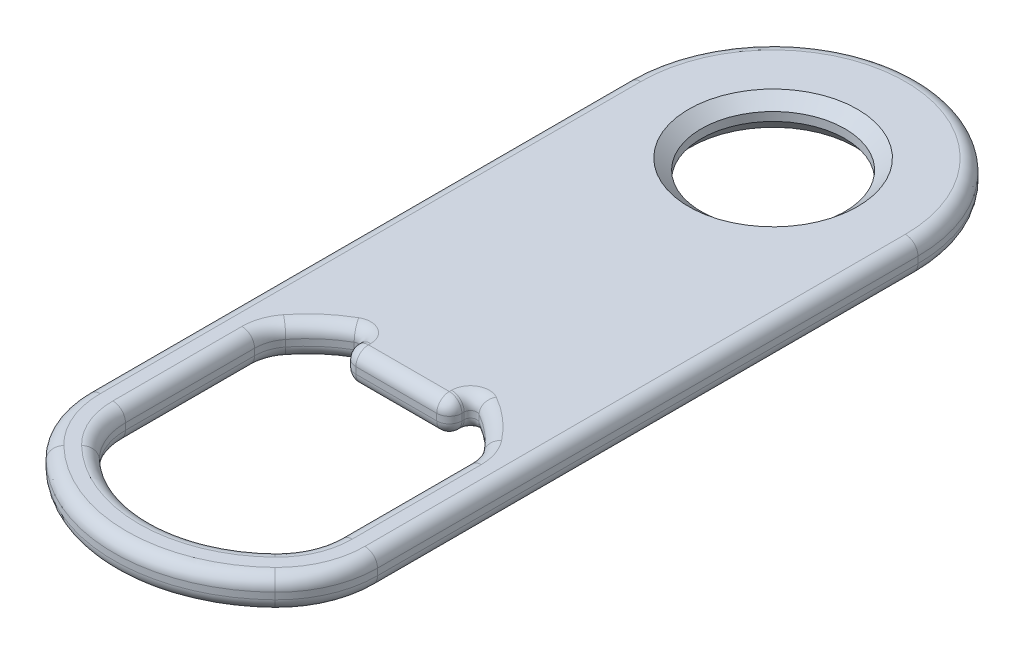
from build123d import *

# Parameters (mm, degrees)
BOSS_EXTRUDE1_DEPTH   = 2.52
CUT_EXTRUDE1_DEPTH    = 10
FILLET1_R             = 1
FILLET2_R             = 8
FILLET3_R             = 5
FILLET4_R             = 3
FILLET5_R             = 0.5
FILLET6_R             = 1
FILLET7_R             = 1
CHAMFER1_SIZE         = 1
CHAMFER1_SIZE2        = 0.839099631
CHAMFER1_PART_2_SIZE  = 1
CHAMFER1_PART_2_SIZE2 = 0.839099631


with BuildPart() as part:
    # Sketch3 → Boss-Extrude1 (new body)
    with BuildSketch(Plane(origin=(0, 11.24, 0), x_dir=(0, 0, 1), z_dir=(0, -1, 0))):
        with BuildLine():
            Line((-5.7, 0), (-12.000001825, 0))
            Line((-12.000001825, 0), (-12.000001825, 11.5))
            Line((-12.000001825, 11.5), (45.406310527, 11.5))
            ThreePointArc((45.406310527, 11.5), (50.46030749, 6.709778353), (52.322559669, 0))
            Line((52.322559669, 0), (49.322559669, 0))
            ThreePointArc((49.322559669, 0), (48.068036881, 4.857481326), (44.618252316, 8.499999508))
            Line((44.618252316, 8.499999508), (31.732809444, 8.499999508))
            ThreePointArc((31.732809444, 8.499999508), (29.503647996, 6.63570395), (27.906627074, 4.207889529))
            Line((27.906627074, 4.207889529), (29.906623676, 4.207889529))
            Line((29.906623676, 4.207889529), (29.906623676, 0))
            Line((29.906623676, 0), (5.7, 0))
            ThreePointArc((5.7, 0), (0, 5.7), (-5.7, 0))
        make_face()
    extrude(amount=-BOSS_EXTRUDE1_DEPTH)

    # Sketch5 → Cut-Extrude1 (cut)
    with BuildSketch(Plane(origin=(0, 11.24, 0), x_dir=(0, 0, 1), z_dir=(0, -1, 0))):
        with BuildLine():
            Line((0, 11.5), (0, 20.081542109))
            Line((0, 20.081542109), (-17.206571574, 20.081542109))
            Line((-17.206571574, 20.081542109), (-17.206571574, -3.325861619))
            Line((-17.206571574, -3.325861619), (-11.00857141, -3.325861619))
            ThreePointArc((-11.00857141, -3.325861619), (-9.23302249, 6.855749098), (0, 11.5))
        make_face()
    extrude(amount=-CUT_EXTRUDE1_DEPTH, mode=Mode.SUBTRACT)

    # Fillet1
    fillet1_edges = [part.edges().sort_by_distance(p)[0] for p in [
        (-4.207889529, 12.5, 29.906623676),
    ]]
    fillet(fillet1_edges, radius=FILLET1_R)

    # Fillet2
    fillet2_edges = [part.edges().sort_by_distance(p)[0] for p in [
        (-11.5, 12.5, 45.406310527),
    ]]
    fillet(fillet2_edges, radius=FILLET2_R)

    # Fillet3
    fillet3_edges = [part.edges().sort_by_distance(p)[0] for p in [
        (-8.499999508, 12.5, 44.618252316),
    ]]
    fillet(fillet3_edges, radius=FILLET3_R)

    # Fillet4
    fillet4_edges = [part.edges().sort_by_distance(p)[0] for p in [
        (-8.499999508, 12.5, 31.732809444),
    ]]
    fillet(fillet4_edges, radius=FILLET4_R)

    # Fillet5
    fillet5_edges = [part.edges().sort_by_distance(p)[0] for p in [
        (-4.207889529, 12.5, 27.906627074),
    ]]
    fillet(fillet5_edges, radius=FILLET5_R)

    # Fillet6
    fillet6_edges = [part.edges().sort_by_distance(p)[0] for p in [
        (-4.899665378, 11.24, 51.36538086),
        (-8.131727984, 11.24, -8.131727984),
        (-4.899665378, 13.76, 51.36538086),
        (-8.131727984, 13.76, -8.131727984),
        (-11.5, 11.24, 21.45040417),
        (-10.869902111, 11.24, 46.012808159),
        (-11.5, 13.76, 21.45040417),
        (-10.869902111, 13.76, 46.012808159),
    ]]
    fillet(fillet6_edges, radius=FILLET6_R)

    # Fillet7
    fillet7_edges = [part.edges().sort_by_distance(p)[0] for p in [
        (-1.603944764, 13.76, 29.906623676),
        (-1.603944764, 11.24, 29.906623676),
        (-4.207889529, 11.24, 28.817398931),
        (-3.91499631, 11.24, 29.613730457),
        (-4.207889529, 13.76, 28.817398931),
        (-3.91499631, 13.76, 29.613730457),
        (-3.764181528, 11.24, 48.589533472),
        (-3.764181528, 13.76, 48.589533472),
        (-8.103866337, 11.24, 44.856156934),
        (-8.103866337, 13.76, 44.856156934),
        (-8.499999508, 13.76, 37.784126486),
        (-8.499999508, 11.24, 37.784126486),
        (-8.337232062, 11.24, 31.68784918),
        (-8.337232062, 13.76, 31.68784918),
        (-6.534576313, 13.76, 29.414716402),
        (-6.534576313, 11.24, 29.414716402),
        (-4.457147388, 11.24, 28.295590808),
        (-4.457147388, 13.76, 28.295590808),
    ]]
    fillet(fillet7_edges, radius=FILLET7_R)

    # Chamfer1
    chamfer1_edges = [part.edges().sort_by_distance(p)[0] for p in [
        (-5.7, 11.24, 0),
    ]]
    chamfer1_side = [part.faces().sort_by_distance(p)[0] for p in [
        (-5.7, 12.5, 0),
    ]]
    chamfer(chamfer1_edges, length=CHAMFER1_SIZE, length2=CHAMFER1_SIZE2, reference=chamfer1_side[0])

    # Chamfer1 part 2
    chamfer1_part_2_edges = [part.edges().sort_by_distance(p)[0] for p in [
        (-5.7, 13.76, 0),
    ]]
    chamfer1_part_2_side = [part.faces().sort_by_distance(p)[0] for p in [
        (-5.701281464, 13.76, 14.029181163),
    ]]
    chamfer(chamfer1_part_2_edges, length=CHAMFER1_PART_2_SIZE, length2=CHAMFER1_PART_2_SIZE2, reference=chamfer1_part_2_side[0])

    # Mirror1: part across plane


with BuildPart() as part_1:
    add(part.part)
    add(part.part.mirror(Plane(origin=(0, 0, 0), x_dir=(0, 0, 1), z_dir=(1, 0, 0))))


solid = part_1.part
